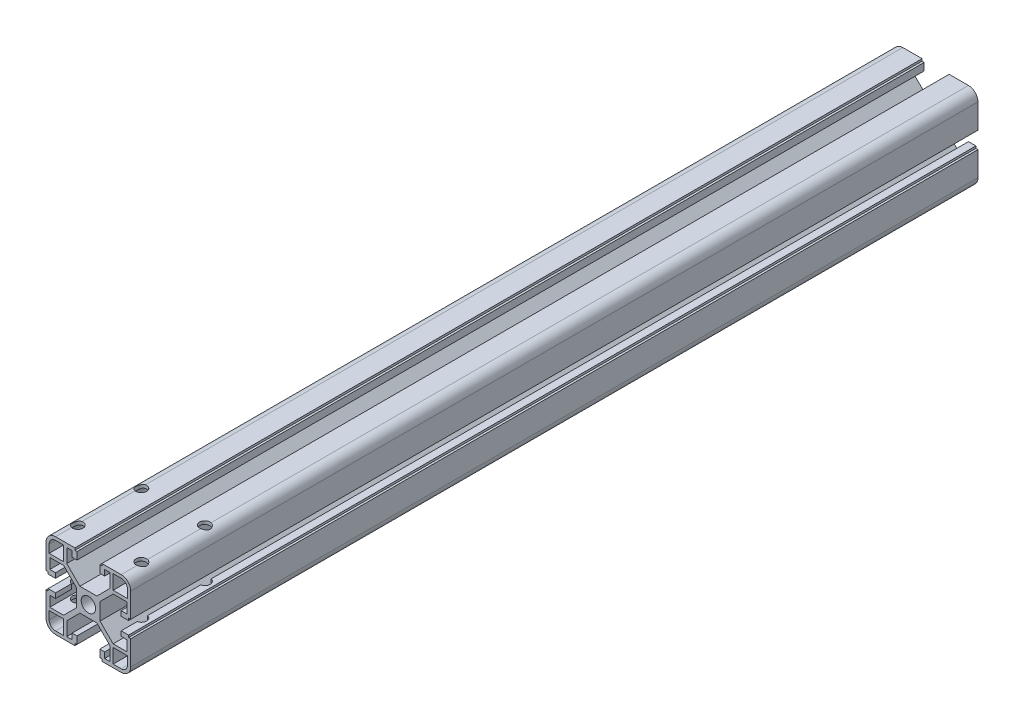
from build123d import *

# Parameters (mm, degrees)
BOSS_EXTRUDE1_DEPTH     = 400
MIRROR3_COPY_1_DEPTH    = 400
MIRROR3_COPY_2_DEPTH    = 400
SKETCH2_R               = 2.5
CUT_EXTRUDE1_DEPTH      = 15.5
CUT_EXTRUDE1_DEPTH_BACK = 26.5


with BuildPart() as part:
    # Sketch1 → Boss-Extrude1 (new body)
    with BuildSketch(Plane.XY):
        with BuildLine():
            Line((3.4, 0), (5.5, 0))
            Line((5.5, 0), (5.5, 4))
            Line((5.5, 4), (11.69, 10.19))
            Line((11.69, 10.19), (18.2, 10.19))
            Line((18.2, 10.19), (18.2, 5.265595036))
            Line((18.2, 5.265595036), (15.5, 5.265595036))
            Line((15.5, 5.265595036), (15.5, 2.965595036))
            Line((15.5, 2.965595036), (19, 2.965595036))
            Line((19, 2.965595036), (19, 3.965595036))
            Line((19, 3.965595036), (20, 3.965595036))
            Line((20, 3.965595036), (20, 15.5))
            ThreePointArc((20, 15.5), (18.681980515, 18.681980515), (15.5, 20))
            Line((15.5, 20), (6.385304712, 20))
            Line((6.385304712, 20), (6.385304712, 19))
            Line((6.385304712, 19), (5.385304712, 19))
            Line((5.385304712, 19), (5.385304712, 15.5))
            Line((5.385304712, 15.5), (7.685304712, 15.5))
            Line((7.685304712, 15.5), (7.685304712, 18.2))
            Line((7.685304712, 18.2), (10.19, 18.2))
            Line((10.19, 18.2), (10.19, 11.69))
            Line((10.19, 11.69), (4, 5.5))
            Line((4, 5.5), (0, 5.5))
            Line((0, 5.5), (0, 3.4))
            ThreePointArc((0, 3.4), (2.404163056, 2.404163056), (3.4, 0))
        make_face()
        with BuildLine():
            Line((18.5, 11.69), (18.5, 15.5))
            ThreePointArc((18.5, 15.5), (17.621320344, 17.621320344), (15.5, 18.5))
            Line((15.5, 18.5), (11.69, 18.5))
            Line((11.69, 18.5), (11.69, 11.69))
            Line((11.69, 11.69), (18.5, 11.69))
        make_face(mode=Mode.SUBTRACT)
    boss_extrude1 = extrude(amount=BOSS_EXTRUDE1_DEPTH)

    # Mirror1: Boss-Extrude1 across plane
    add(boss_extrude1.mirror(Plane.ZX))

    # Mirror2: Boss-Extrude1 across plane
    add(boss_extrude1.mirror(Plane(origin=(0, 0, 0), x_dir=(0, 0, 1), z_dir=(1, 0, 0))))

    # Mirror3 copy 1 sketch → Mirror3 copy 1 (add)
    with BuildSketch(Plane(origin=(0, 0, 0), x_dir=(-1, 0, 0), z_dir=(0, 0, 1))):
        with BuildLine():
            Line((3.4, 0), (5.5, 0))
            Line((5.5, 0), (5.5, 4))
            Line((5.5, 4), (11.69, 10.19))
            Line((11.69, 10.19), (18.2, 10.19))
            Line((18.2, 10.19), (18.2, 5.265595036))
            Line((18.2, 5.265595036), (15.5, 5.265595036))
            Line((15.5, 5.265595036), (15.5, 2.965595036))
            Line((15.5, 2.965595036), (19, 2.965595036))
            Line((19, 2.965595036), (19, 3.965595036))
            Line((19, 3.965595036), (20, 3.965595036))
            Line((20, 3.965595036), (20, 15.5))
            ThreePointArc((20, 15.5), (18.681980515, 18.681980515), (15.5, 20))
            Line((15.5, 20), (6.385304712, 20))
            Line((6.385304712, 20), (6.385304712, 19))
            Line((6.385304712, 19), (5.385304712, 19))
            Line((5.385304712, 19), (5.385304712, 15.5))
            Line((5.385304712, 15.5), (7.685304712, 15.5))
            Line((7.685304712, 15.5), (7.685304712, 18.2))
            Line((7.685304712, 18.2), (10.19, 18.2))
            Line((10.19, 18.2), (10.19, 11.69))
            Line((10.19, 11.69), (4, 5.5))
            Line((4, 5.5), (0, 5.5))
            Line((0, 5.5), (0, 3.4))
            ThreePointArc((0, 3.4), (2.404163056, 2.404163056), (3.4, 0))
        make_face()
        with BuildLine():
            Line((18.5, 11.69), (18.5, 15.5))
            ThreePointArc((18.5, 15.5), (17.621320344, 17.621320344), (15.5, 18.5))
            Line((15.5, 18.5), (11.69, 18.5))
            Line((11.69, 18.5), (11.69, 11.69))
            Line((11.69, 11.69), (18.5, 11.69))
        make_face(mode=Mode.SUBTRACT)
    extrude(amount=MIRROR3_COPY_1_DEPTH)

    # Mirror3 copy 2 sketch → Mirror3 copy 2 (add)
    with BuildSketch(Plane.XY):
        with BuildLine():
            Line((3.4, 0), (5.5, 0))
            Line((5.5, 0), (5.5, -4))
            Line((5.5, -4), (11.69, -10.19))
            Line((11.69, -10.19), (18.2, -10.19))
            Line((18.2, -10.19), (18.2, -5.265595036))
            Line((18.2, -5.265595036), (15.5, -5.265595036))
            Line((15.5, -5.265595036), (15.5, -2.965595036))
            Line((15.5, -2.965595036), (19, -2.965595036))
            Line((19, -2.965595036), (19, -3.965595036))
            Line((19, -3.965595036), (20, -3.965595036))
            Line((20, -3.965595036), (20, -15.5))
            ThreePointArc((20, -15.5), (18.681980515, -18.681980515), (15.5, -20))
            Line((15.5, -20), (6.385304712, -20))
            Line((6.385304712, -20), (6.385304712, -19))
            Line((6.385304712, -19), (5.385304712, -19))
            Line((5.385304712, -19), (5.385304712, -15.5))
            Line((5.385304712, -15.5), (7.685304712, -15.5))
            Line((7.685304712, -15.5), (7.685304712, -18.2))
            Line((7.685304712, -18.2), (10.19, -18.2))
            Line((10.19, -18.2), (10.19, -11.69))
            Line((10.19, -11.69), (4, -5.5))
            Line((4, -5.5), (0, -5.5))
            Line((0, -5.5), (0, -3.4))
            ThreePointArc((0, -3.4), (2.404163056, -2.404163056), (3.4, 0))
        make_face()
        with BuildLine():
            Line((18.5, -11.69), (18.5, -15.5))
            ThreePointArc((18.5, -15.5), (17.621320344, -17.621320344), (15.5, -18.5))
            Line((15.5, -18.5), (11.69, -18.5))
            Line((11.69, -18.5), (11.69, -11.69))
            Line((11.69, -11.69), (18.5, -11.69))
        make_face(mode=Mode.SUBTRACT)
    extrude(amount=MIRROR3_COPY_2_DEPTH)

    # Sketch2 → Cut-Extrude1 (cut, two sides)
    with BuildSketch(Plane(origin=(0, 5.5, 0), x_dir=(1, 0, 0), z_dir=(0, 1, 0))) as cut_extrude1_sk:
        with Locations((0, -10)):
            Circle(SKETCH2_R)
        with Locations((0, -60)):
            Circle(SKETCH2_R)
        with Locations((-15, -360)):
            Circle(SKETCH2_R)
        with Locations((15, -360)):
            Circle(SKETCH2_R)
        with Locations((15, -390)):
            Circle(SKETCH2_R)
        with Locations((-15, -390)):
            Circle(SKETCH2_R)
    extrude(amount=CUT_EXTRUDE1_DEPTH, mode=Mode.SUBTRACT)
    extrude(cut_extrude1_sk.sketch, amount=-CUT_EXTRUDE1_DEPTH_BACK, mode=Mode.SUBTRACT)


solid = part.part
